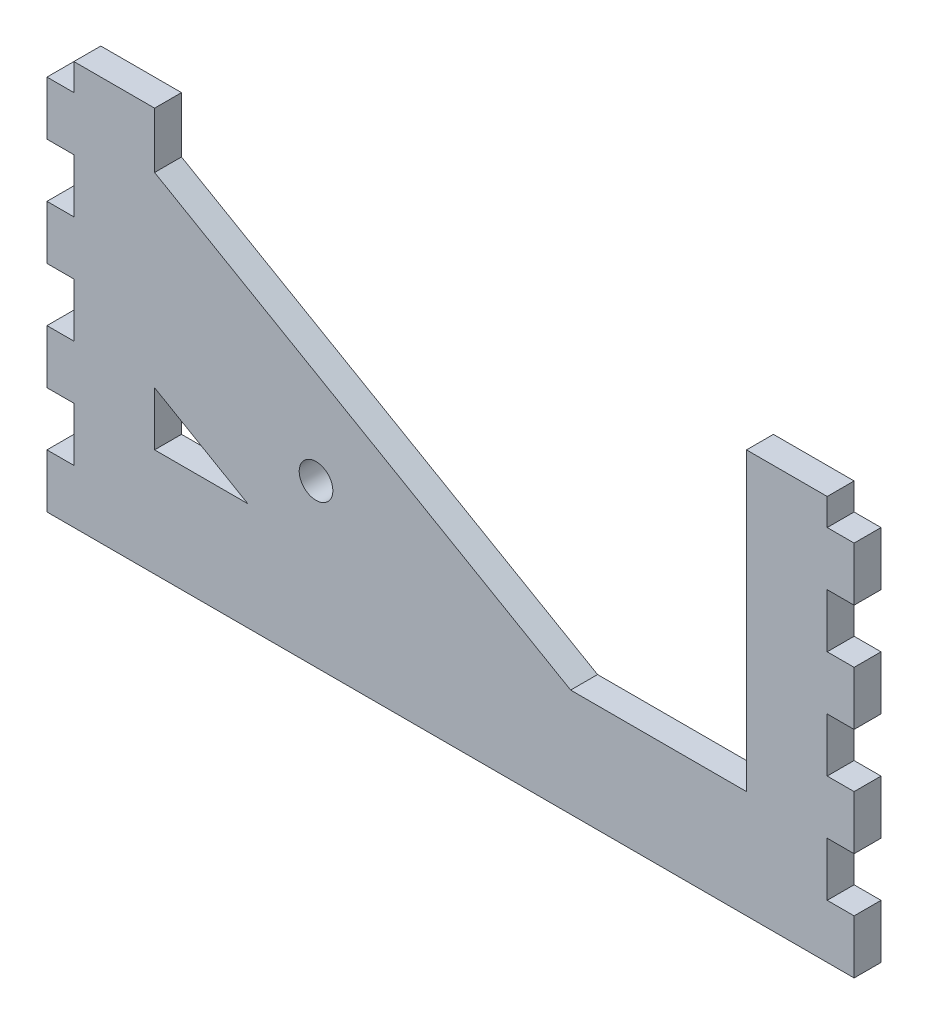
from build123d import *

# Parameters (mm, degrees)
SKETCH1_W           = 190.5
SKETCH1_H           = 95.25
BOSS_EXTRUDE1_DEPTH = 6.35
SKETCH2_R           = 3.96875
CUT_EXTRUDE1_DEPTH  = 7.35
SKETCH3_W           = 6.35
SKETCH3_H           = 12.7
CUT_EXTRUDE2_DEPTH  = 7.35
SKETCH4_W           = 6.35
SKETCH4_H           = 12.7
CUT_EXTRUDE3_DEPTH  = 7.35
LPATTERN1_COUNT     = 4
LPATTERN1_PITCH     = 25.4
CUT_EXTRUDE4_DEPTH  = 7.35


with BuildPart() as part:
    # Sketch1 → Boss-Extrude1 (new body)
    with BuildSketch(Plane.XY):
        with Locations((95.25, 47.625)):
            Rectangle(SKETCH1_W, SKETCH1_H)
    extrude(amount=BOSS_EXTRUDE1_DEPTH)

    # Sketch2 → Cut-Extrude1 (cut, through all)
    with BuildSketch(Plane.XY.offset(6.35)):
        with Locations((63.5, 38.1)):
            Circle(SKETCH2_R)
    extrude(amount=-CUT_EXTRUDE1_DEPTH, mode=Mode.SUBTRACT)

    # Sketch3 → Cut-Extrude2 (cut, through all)
    with BuildSketch(Plane.XY.offset(6.35)):
        with Locations((3.175, 19.05)):
            Rectangle(SKETCH3_W, SKETCH3_H)
    cut_extrude2 = extrude(amount=-CUT_EXTRUDE2_DEPTH, mode=Mode.SUBTRACT)

    # Sketch4 → Cut-Extrude3 (cut, through all)
    with BuildSketch(Plane.XY.offset(6.35)):
        with Locations((187.325, 19.05)):
            Rectangle(SKETCH4_W, SKETCH4_H)
    cut_extrude3 = extrude(amount=-CUT_EXTRUDE3_DEPTH, mode=Mode.SUBTRACT)

    # LPattern1: Cut-Extrude2, Cut-Extrude3 ×4
    with Locations(*[(0, i * LPATTERN1_PITCH, 0) for i in range(1, LPATTERN1_COUNT)]):
        add(cut_extrude2, mode=Mode.SUBTRACT)
        add(cut_extrude3, mode=Mode.SUBTRACT)

    # Sketch6 → Cut-Extrude4 (cut, through all)
    with BuildSketch(Plane.XY.offset(6.35)):
        Polygon((25.4, 95.25), (25.4, 82.094090512), (123.597045256, 25.4), (165.1, 25.4), (165.1, 95.25), align=None)
        Polygon((25.4, 38.1), (25.4, 25.4), (47.397045256, 25.4), align=None)
    extrude(amount=-CUT_EXTRUDE4_DEPTH, mode=Mode.SUBTRACT)


solid = part.part
